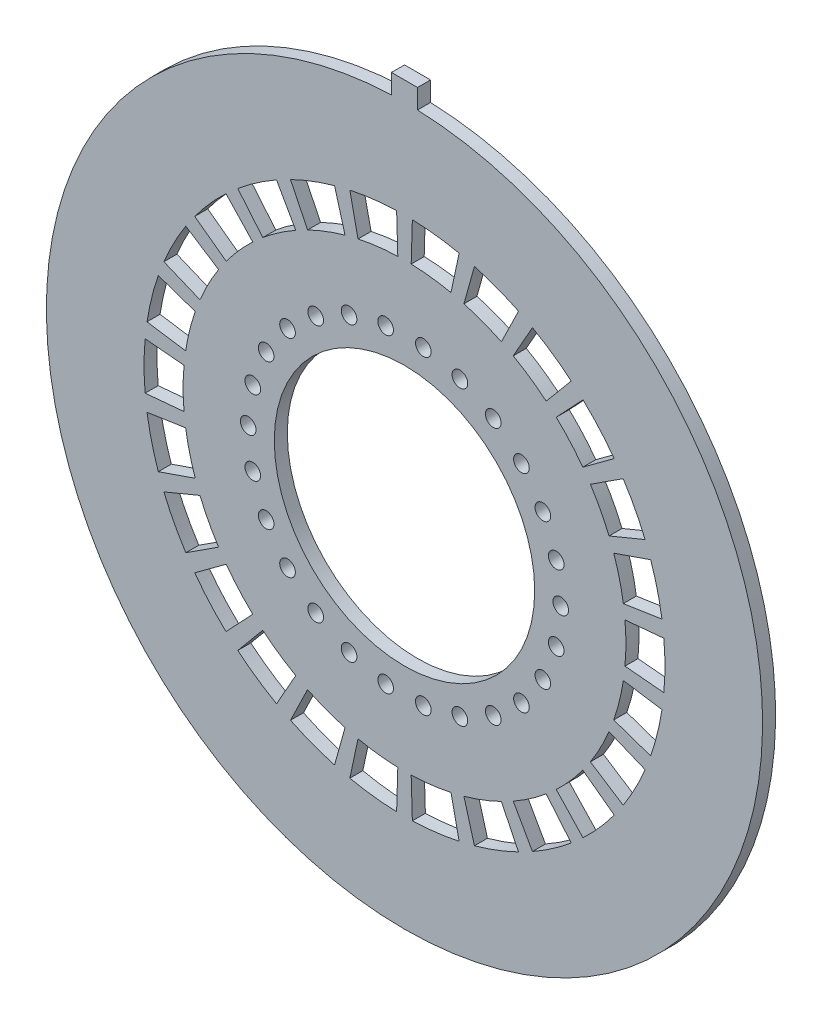
from build123d import *

# Parameters (mm, degrees)
PCB_DIMENSION_R     = 0.6
PCB_DIMENSION_R_2   = 10
BOSS_EXTRUDE1_DEPTH = 1
CUT_EXTRUDE1_DEPTH  = 2


with BuildPart() as part:
    # PCB dimension → Boss-Extrude1 (new body)
    with BuildSketch(Plane.XY):
        with BuildLine():
            Line((-1, 27.481812167), (-1, 28.981812167))
            Line((-1, 28.981812167), (1, 28.981812167))
            Line((1, 28.981812167), (1, 27.481812167))
            ThreePointArc((1, 27.481812167), (0, -27.5), (-1, 27.481812167))
        make_face()
        with Locations((12, 0)):
            Circle(PCB_DIMENSION_R, mode=Mode.SUBTRACT)
        with Locations((11.651301809, -2.871787971)):
            Circle(PCB_DIMENSION_R, mode=Mode.SUBTRACT)
        with Locations((10.625472308, -5.576678065)):
            Circle(PCB_DIMENSION_R, mode=Mode.SUBTRACT)
        with Locations((8.982128978, -7.957471899)):
            Circle(PCB_DIMENSION_R, mode=Mode.SUBTRACT)
        with Locations((6.816776961, -9.875806391)):
            Circle(PCB_DIMENSION_R, mode=Mode.SUBTRACT)
        with Locations((4.255258645, -11.220194912)):
            Circle(PCB_DIMENSION_R, mode=Mode.SUBTRACT)
        with Locations((1.446440163, -11.912506489)):
            Circle(PCB_DIMENSION_R, mode=Mode.SUBTRACT)
        with Locations((-1.446440163, -11.912506489)):
            Circle(PCB_DIMENSION_R, mode=Mode.SUBTRACT)
        with Locations((-4.255258645, -11.220194912)):
            Circle(PCB_DIMENSION_R, mode=Mode.SUBTRACT)
        with Locations((-6.816776961, -9.875806391)):
            Circle(PCB_DIMENSION_R, mode=Mode.SUBTRACT)
        with Locations((-8.982128978, -7.957471899)):
            Circle(PCB_DIMENSION_R, mode=Mode.SUBTRACT)
        with Locations((-10.625472308, -5.576678065)):
            Circle(PCB_DIMENSION_R, mode=Mode.SUBTRACT)
        with Locations((-11.651301809, -2.871787971)):
            Circle(PCB_DIMENSION_R, mode=Mode.SUBTRACT)
        with Locations((-12, 0)):
            Circle(PCB_DIMENSION_R, mode=Mode.SUBTRACT)
        with Locations((-11.651301809, 2.871787971)):
            Circle(PCB_DIMENSION_R, mode=Mode.SUBTRACT)
        with Locations((-10.625472308, 5.576678065)):
            Circle(PCB_DIMENSION_R, mode=Mode.SUBTRACT)
        with Locations((-8.982128978, 7.957471899)):
            Circle(PCB_DIMENSION_R, mode=Mode.SUBTRACT)
        with Locations((-6.816776961, 9.875806391)):
            Circle(PCB_DIMENSION_R, mode=Mode.SUBTRACT)
        with Locations((-4.255258645, 11.220194912)):
            Circle(PCB_DIMENSION_R, mode=Mode.SUBTRACT)
        with Locations((-1.446440163, 11.912506489)):
            Circle(PCB_DIMENSION_R, mode=Mode.SUBTRACT)
        with Locations((1.446440163, 11.912506489)):
            Circle(PCB_DIMENSION_R, mode=Mode.SUBTRACT)
        with Locations((4.255258645, 11.220194912)):
            Circle(PCB_DIMENSION_R, mode=Mode.SUBTRACT)
        with Locations((6.816776961, 9.875806391)):
            Circle(PCB_DIMENSION_R, mode=Mode.SUBTRACT)
        with Locations((8.982128978, 7.957471899)):
            Circle(PCB_DIMENSION_R, mode=Mode.SUBTRACT)
        with Locations((10.625472308, 5.576678065)):
            Circle(PCB_DIMENSION_R, mode=Mode.SUBTRACT)
        with Locations((11.651301809, 2.871787971)):
            Circle(PCB_DIMENSION_R, mode=Mode.SUBTRACT)
        Circle(PCB_DIMENSION_R_2, mode=Mode.SUBTRACT)
    extrude(amount=BOSS_EXTRUDE1_DEPTH)

    # Sketch1 → Cut-Extrude1 (cut, through all)
    with BuildSketch(Plane.XY.offset(1)):
        with BuildLine():
            Line((16.930241479, 1.538480889), (19.917931152, 1.809977517))
            ThreePointArc((19.917931152, 1.809977517), (20, 0), (19.917931152, -1.809977517))
            Line((19.917931152, -1.809977517), (16.930241479, -1.538480889))
            ThreePointArc((16.930241479, -1.538480889), (17, 0), (16.930241479, 1.538480889))
        make_face()
        with BuildLine():
            Line((18.905996301, -6.524055784), (16.070096856, -5.545447417))
            ThreePointArc((16.070096856, -5.545447417), (16.506010896, -4.068366293), (16.806462008, -2.557896556))
            Line((16.806462008, -2.557896556), (19.772308244, -3.009290065))
            ThreePointArc((19.772308244, -3.009290065), (19.418836349, -4.786313286), (18.905996301, -6.524055784))
        make_face()
        with BuildLine():
            Line((16.795313665, -10.858979644), (14.276016615, -9.230132697))
            ThreePointArc((14.276016615, -9.230132697), (15.052752436, -7.900293925), (15.705952053, -6.50561835))
            Line((15.705952053, -6.50561835), (18.47759065, -7.653668647))
            ThreePointArc((18.47759065, -7.653668647), (17.709120513, -9.294463441), (16.795313665, -10.858979644))
        make_face()
        with BuildLine():
            Line((13.708548447, -14.562819078), (11.65226618, -12.378396216))
            ThreePointArc((11.65226618, -12.378396216), (12.724682719, -11.27308519), (13.692669253, -10.075257253))
            Line((13.692669253, -10.075257253), (16.109022651, -11.853243827))
            ThreePointArc((16.109022651, -11.853243827), (14.970214963, -13.262453165), (13.708548447, -14.562819078))
        make_face()
        with BuildLine():
            Line((9.825092222, -17.4203204), (8.351328388, -14.80727234))
            ThreePointArc((8.351328388, -14.80727234), (9.657100694, -13.99072572), (10.883618288, -13.059358827))
            Line((10.883618288, -13.059358827), (12.804256809, -15.363951561))
            ThreePointArc((12.804256809, -15.363951561), (11.361294935, -16.459677318), (9.825092222, -17.4203204))
        make_face()
        with BuildLine():
            Line((5.370637349, -19.265416021), (4.565041747, -16.375603618))
            ThreePointArc((4.565041747, -16.375603618), (6.02828308, -15.895276126), (7.442050988, -15.284497934))
            Line((7.442050988, -15.284497934), (8.755354103, -17.981762275))
            ThreePointArc((8.755354103, -17.981762275), (7.092097741, -18.700324854), (5.370637349, -19.265416021))
        make_face()
        with BuildLine():
            Line((0.604060556, -19.99087569), (0.513451473, -16.992244336))
            ThreePointArc((0.513451473, -16.992244336), (2.049123564, -16.87605086), (3.567978735, -16.621357578))
            Line((3.567978735, -16.621357578), (4.197622041, -19.554538327))
            ThreePointArc((4.197622041, -19.554538327), (2.410733605, -19.854177482), (0.604060556, -19.99087569))
        make_face()
        with BuildLine():
            Line((-4.197622041, -19.554538327), (-3.567978735, -16.621357578))
            ThreePointArc((-3.567978735, -16.621357578), (-2.049123564, -16.87605086), (-0.513451473, -16.992244336))
            Line((-0.513451473, -16.992244336), (-0.604060556, -19.99087569))
            ThreePointArc((-0.604060556, -19.99087569), (-2.410733605, -19.854177482), (-4.197622041, -19.554538327))
        make_face()
        with BuildLine():
            Line((-8.755354103, -17.981762275), (-7.442050988, -15.284497934))
            ThreePointArc((-7.442050988, -15.284497934), (-6.02828308, -15.895276126), (-4.565041747, -16.375603618))
            Line((-4.565041747, -16.375603618), (-5.370637349, -19.265416021))
            ThreePointArc((-5.370637349, -19.265416021), (-7.092097741, -18.700324854), (-8.755354103, -17.981762275))
        make_face()
        with BuildLine():
            Line((-12.804256809, -15.363951561), (-10.883618288, -13.059358827))
            ThreePointArc((-10.883618288, -13.059358827), (-9.657100694, -13.99072572), (-8.351328388, -14.80727234))
            Line((-8.351328388, -14.80727234), (-9.825092222, -17.4203204))
            ThreePointArc((-9.825092222, -17.4203204), (-11.361294935, -16.459677318), (-12.804256809, -15.363951561))
        make_face()
        with BuildLine():
            Line((-16.109022651, -11.853243827), (-13.692669253, -10.075257253))
            ThreePointArc((-13.692669253, -10.075257253), (-12.724682719, -11.27308519), (-11.65226618, -12.378396216))
            Line((-11.65226618, -12.378396216), (-13.708548447, -14.562819078))
            ThreePointArc((-13.708548447, -14.562819078), (-14.970214963, -13.262453165), (-16.109022651, -11.853243827))
        make_face()
        with BuildLine():
            Line((-18.47759065, -7.653668647), (-15.705952053, -6.50561835))
            ThreePointArc((-15.705952053, -6.50561835), (-15.052752436, -7.900293925), (-14.276016615, -9.230132697))
            Line((-14.276016615, -9.230132697), (-16.795313665, -10.858979644))
            ThreePointArc((-16.795313665, -10.858979644), (-17.709120513, -9.294463441), (-18.47759065, -7.653668647))
        make_face()
        with BuildLine():
            Line((-19.772308244, -3.009290065), (-16.806462008, -2.557896556))
            ThreePointArc((-16.806462008, -2.557896556), (-16.506010896, -4.068366293), (-16.070096856, -5.545447417))
            Line((-16.070096856, -5.545447417), (-18.905996301, -6.524055784))
            ThreePointArc((-18.905996301, -6.524055784), (-19.418836349, -4.786313286), (-19.772308244, -3.009290065))
        make_face()
        with BuildLine():
            Line((-19.917931152, 1.809977517), (-16.930241479, 1.538480889))
            ThreePointArc((-16.930241479, 1.538480889), (-17, 0), (-16.930241479, -1.538480889))
            Line((-16.930241479, -1.538480889), (-19.917931152, -1.809977517))
            ThreePointArc((-19.917931152, -1.809977517), (-20, 0), (-19.917931152, 1.809977517))
        make_face()
        with BuildLine():
            Line((-18.905996301, 6.524055784), (-16.070096856, 5.545447417))
            ThreePointArc((-16.070096856, 5.545447417), (-16.506010896, 4.068366293), (-16.806462008, 2.557896556))
            Line((-16.806462008, 2.557896556), (-19.772308244, 3.009290065))
            ThreePointArc((-19.772308244, 3.009290065), (-19.418836349, 4.786313286), (-18.905996301, 6.524055784))
        make_face()
        with BuildLine():
            Line((-16.795313665, 10.858979644), (-14.276016615, 9.230132697))
            ThreePointArc((-14.276016615, 9.230132697), (-15.052752436, 7.900293925), (-15.705952053, 6.50561835))
            Line((-15.705952053, 6.50561835), (-18.47759065, 7.653668647))
            ThreePointArc((-18.47759065, 7.653668647), (-17.709120513, 9.294463441), (-16.795313665, 10.858979644))
        make_face()
        with BuildLine():
            Line((-13.708548447, 14.562819078), (-11.65226618, 12.378396216))
            ThreePointArc((-11.65226618, 12.378396216), (-12.724682719, 11.27308519), (-13.692669253, 10.075257253))
            Line((-13.692669253, 10.075257253), (-16.109022651, 11.853243827))
            ThreePointArc((-16.109022651, 11.853243827), (-14.970214963, 13.262453165), (-13.708548447, 14.562819078))
        make_face()
        with BuildLine():
            Line((-9.825092222, 17.4203204), (-8.351328388, 14.80727234))
            ThreePointArc((-8.351328388, 14.80727234), (-9.657100694, 13.99072572), (-10.883618288, 13.059358827))
            Line((-10.883618288, 13.059358827), (-12.804256809, 15.363951561))
            ThreePointArc((-12.804256809, 15.363951561), (-11.361294935, 16.459677318), (-9.825092222, 17.4203204))
        make_face()
        with BuildLine():
            Line((-5.370637349, 19.265416021), (-4.565041747, 16.375603618))
            ThreePointArc((-4.565041747, 16.375603618), (-6.02828308, 15.895276126), (-7.442050988, 15.284497934))
            Line((-7.442050988, 15.284497934), (-8.755354103, 17.981762275))
            ThreePointArc((-8.755354103, 17.981762275), (-7.092097741, 18.700324854), (-5.370637349, 19.265416021))
        make_face()
        with BuildLine():
            Line((-0.604060556, 19.99087569), (-0.513451473, 16.992244336))
            ThreePointArc((-0.513451473, 16.992244336), (-2.049123564, 16.87605086), (-3.567978735, 16.621357578))
            Line((-3.567978735, 16.621357578), (-4.197622041, 19.554538327))
            ThreePointArc((-4.197622041, 19.554538327), (-2.410733605, 19.854177482), (-0.604060556, 19.99087569))
        make_face()
        with BuildLine():
            Line((4.197622041, 19.554538327), (3.567978735, 16.621357578))
            ThreePointArc((3.567978735, 16.621357578), (2.049123564, 16.87605086), (0.513451473, 16.992244336))
            Line((0.513451473, 16.992244336), (0.604060556, 19.99087569))
            ThreePointArc((0.604060556, 19.99087569), (2.410733605, 19.854177482), (4.197622041, 19.554538327))
        make_face()
        with BuildLine():
            Line((8.755354103, 17.981762275), (7.442050988, 15.284497934))
            ThreePointArc((7.442050988, 15.284497934), (6.02828308, 15.895276126), (4.565041747, 16.375603618))
            Line((4.565041747, 16.375603618), (5.370637349, 19.265416021))
            ThreePointArc((5.370637349, 19.265416021), (7.092097741, 18.700324854), (8.755354103, 17.981762275))
        make_face()
        with BuildLine():
            Line((12.804256809, 15.363951561), (10.883618288, 13.059358827))
            ThreePointArc((10.883618288, 13.059358827), (9.657100694, 13.99072572), (8.351328388, 14.80727234))
            Line((8.351328388, 14.80727234), (9.825092222, 17.4203204))
            ThreePointArc((9.825092222, 17.4203204), (11.361294935, 16.459677318), (12.804256809, 15.363951561))
        make_face()
        with BuildLine():
            Line((16.109022651, 11.853243827), (13.692669253, 10.075257253))
            ThreePointArc((13.692669253, 10.075257253), (12.724682719, 11.27308519), (11.65226618, 12.378396216))
            Line((11.65226618, 12.378396216), (13.708548447, 14.562819078))
            ThreePointArc((13.708548447, 14.562819078), (14.970214963, 13.262453165), (16.109022651, 11.853243827))
        make_face()
        with BuildLine():
            Line((18.47759065, 7.653668647), (15.705952053, 6.50561835))
            ThreePointArc((15.705952053, 6.50561835), (15.052752436, 7.900293925), (14.276016615, 9.230132697))
            Line((14.276016615, 9.230132697), (16.795313665, 10.858979644))
            ThreePointArc((16.795313665, 10.858979644), (17.709120513, 9.294463441), (18.47759065, 7.653668647))
        make_face()
        with BuildLine():
            Line((19.772308244, 3.009290065), (16.806462008, 2.557896556))
            ThreePointArc((16.806462008, 2.557896556), (16.506010896, 4.068366293), (16.070096856, 5.545447417))
            Line((16.070096856, 5.545447417), (18.905996301, 6.524055784))
            ThreePointArc((18.905996301, 6.524055784), (19.418836349, 4.786313286), (19.772308244, 3.009290065))
        make_face()
    extrude(amount=-CUT_EXTRUDE1_DEPTH, mode=Mode.SUBTRACT)


solid = part.part
